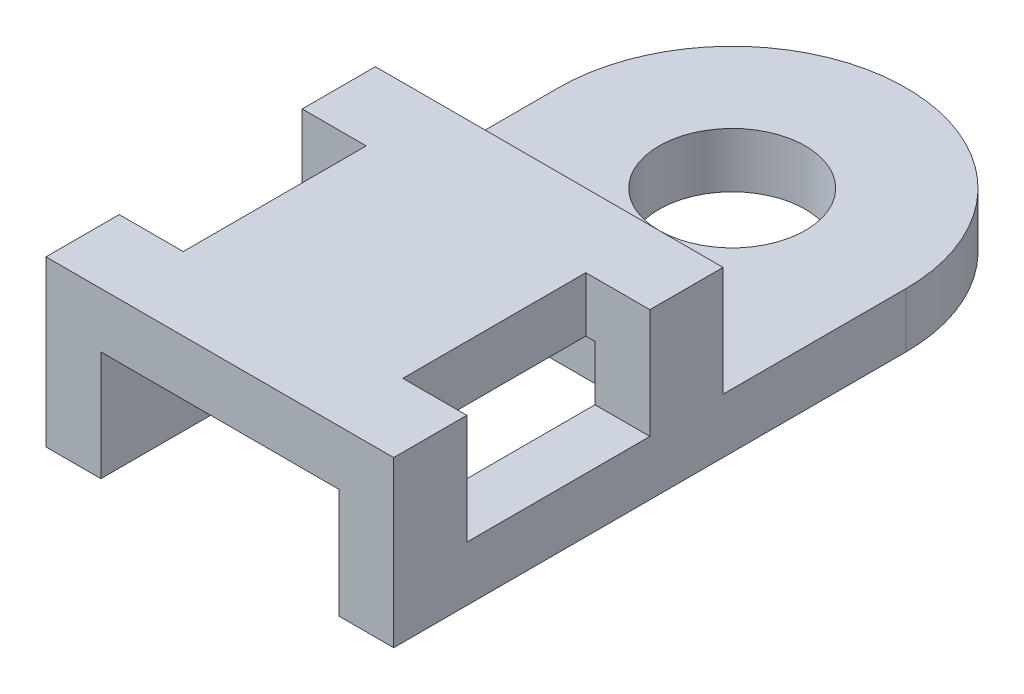
from build123d import *

# Parameters (mm, degrees)
SKETCH_1_R          = 2
EXTRUDE_1_DEPTH     = 1.5
SKETCH_2_W          = 9.5
SKETCH_2_H          = 9
EXTRUDE_2_DEPTH     = 3
SKETCH_3_W          = 6.5
SKETCH_3_H          = 9
CUT_EXTRUDE_1_DEPTH = 3
SKETCH_4_W          = 1.75
SKETCH_4_H          = 5
CUT_EXTRUDE_2_DEPTH = 3


with BuildPart() as part:
    # 草图1 → 凸台-拉伸1 (new body)
    with BuildSketch(Plane(origin=(0, 0, 0), x_dir=(1, 0, 0), z_dir=(0, 1, 0))):
        with BuildLine():
            Line((-4.75, 0), (-4.75, -14))
            Line((-4.75, -14), (4.75, -14))
            Line((4.75, -14), (4.75, 0))
            ThreePointArc((4.75, 0), (0, 4.75), (-4.75, 0))
        make_face()
        Circle(SKETCH_1_R, mode=Mode.SUBTRACT)
    extrude(amount=EXTRUDE_1_DEPTH)

    # 草图2 → 凸台-拉伸2 (add)
    with BuildSketch(Plane(origin=(0, 1.5, 0), x_dir=(1, 0, 0), z_dir=(0, 1, 0))):
        with Locations((0, -9.5)):
            Rectangle(SKETCH_2_W, SKETCH_2_H)
    extrude(amount=EXTRUDE_2_DEPTH)

    # 草图3 → 切除-拉伸1 (cut)
    with BuildSketch(Plane.XZ):
        with Locations((0, 9.5)):
            Rectangle(SKETCH_3_W, SKETCH_3_H)
    extrude(amount=-CUT_EXTRUDE_1_DEPTH, mode=Mode.SUBTRACT)

    # 草图4 → 切除-拉伸2 (cut)
    with BuildSketch(Plane(origin=(0, 4.5, 0), x_dir=(1, 0, 0), z_dir=(0, 1, 0))):
        with Locations((-3.875, -9.5)):
            Rectangle(SKETCH_4_W, SKETCH_4_H)
        with Locations((3.875, -9.5)):
            Rectangle(SKETCH_4_W, SKETCH_4_H)
    extrude(amount=-CUT_EXTRUDE_2_DEPTH, mode=Mode.SUBTRACT)


solid = part.part
